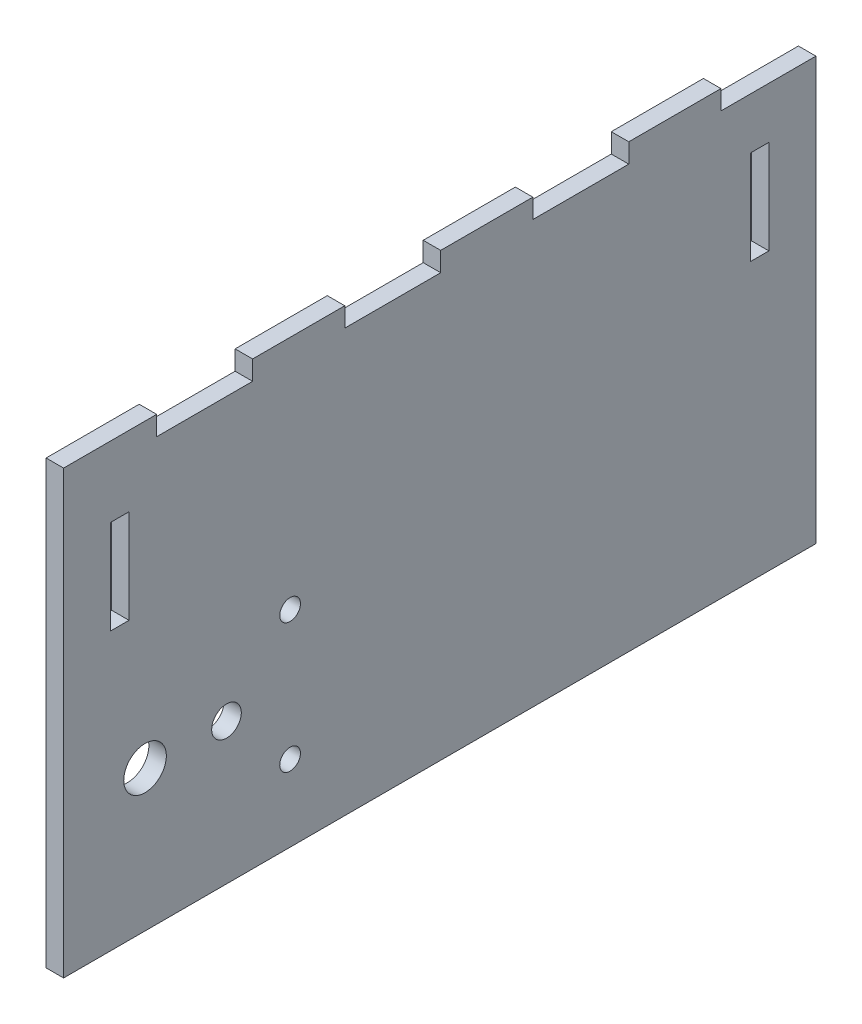
from build123d import *

# Parameters (mm, degrees)
BOSS_EXTRUDE1_DEPTH = 2.3622
CUT_EXTRUDE1_REACH  = 4.362
SKETCH2_R           = 1.4
SKETCH2_R_2         = 2
SKETCH2_R_3         = 2.876999961
CUT_EXTRUDE2_DEPTH  = 3.3622
SKETCH4_W           = 2.4892
SKETCH4_H           = 12.7
CUT_EXTRUDE3_DEPTH  = 3.3622


with BuildPart() as part:
    # Sketch1 → Boss-Extrude1 (new body)
    with BuildSketch(Plane(origin=(0, 0, 0), x_dir=(0, 0, -1), z_dir=(1, 0, 0))):
        Polygon((0, 0), (0, 59.6392), (12.7, 59.6392), (12.7, 57.15), (25.4, 57.15), (25.4, 59.6392), (38.1, 59.6392), (38.1, 57.15), (50.8, 57.15), (50.8, 59.6392), (63.5, 59.6392), (63.5, 57.15), (76.2, 57.15), (76.2, 59.6392), (88.9, 59.6392), (88.9, 57.15), (101.6, 57.15), (101.6, 0), align=None)
    extrude(amount=BOSS_EXTRUDE1_DEPTH)

    # Sketch2 → Cut-Extrude1 (cut, up to next)
    with BuildSketch(Plane(origin=(2.3622, 0, 0), x_dir=(0, 0, -1), z_dir=(1, 0, 0)), mode=Mode.PRIVATE) as cut_extrude1_sk1:
        with Locations((30.59102, 10.3)):
            Circle(SKETCH2_R)
    cut_extrude1_tool1 = extrude(cut_extrude1_sk1.sketch, amount=-CUT_EXTRUDE1_REACH, mode=Mode.PRIVATE) & part.part
    add(cut_extrude1_tool1.solids().sort_by_distance((2.3622, 10.3, -30.59102))[0], mode=Mode.SUBTRACT)
    # Sketch2 → Cut-Extrude1 (cut, up to next)
    with BuildSketch(Plane(origin=(2.3622, 0, 0), x_dir=(0, 0, -1), z_dir=(1, 0, 0)), mode=Mode.PRIVATE) as cut_extrude1_sk2:
        with Locations((30.59102, 27.8)):
            Circle(SKETCH2_R)
    cut_extrude1_tool2 = extrude(cut_extrude1_sk2.sketch, amount=-CUT_EXTRUDE1_REACH, mode=Mode.PRIVATE) & part.part
    add(cut_extrude1_tool2.solids().sort_by_distance((2.3622, 27.8, -30.59102))[0], mode=Mode.SUBTRACT)
    # Sketch2 → Cut-Extrude1 (cut, up to next)
    with BuildSketch(Plane(origin=(2.3622, 0, 0), x_dir=(0, 0, -1), z_dir=(1, 0, 0)), mode=Mode.PRIVATE) as cut_extrude1_sk3:
        with Locations((22.0000034, 19.05)):
            Circle(SKETCH2_R_2)
    cut_extrude1_tool3 = extrude(cut_extrude1_sk3.sketch, amount=-CUT_EXTRUDE1_REACH, mode=Mode.PRIVATE) & part.part
    add(cut_extrude1_tool3.solids().sort_by_distance((2.3622, 19.05, -22.000003))[0], mode=Mode.SUBTRACT)
    # Sketch2 → Cut-Extrude1 (cut, up to next)
    with BuildSketch(Plane(origin=(2.3622, 0, 0), x_dir=(0, 0, -1), z_dir=(1, 0, 0)), mode=Mode.PRIVATE) as cut_extrude1_sk4:
        with Locations((11, 19.05)):
            Circle(SKETCH2_R_3)
    cut_extrude1_tool4 = extrude(cut_extrude1_sk4.sketch, amount=-CUT_EXTRUDE1_REACH, mode=Mode.PRIVATE) & part.part
    add(cut_extrude1_tool4.solids().sort_by_distance((2.3622, 19.05, -11))[0], mode=Mode.SUBTRACT)

    # Sketch3 → Cut-Extrude2 (cut, through all)
    with BuildSketch(Plane(origin=(2.3622, 0, 0), x_dir=(0, 0, -1), z_dir=(1, 0, 0))):
        Polygon((12.7, 57.15), (12.7, 59.6392), (12.573, 59.6392), (12.573, 57.023), (25.527, 57.023), (25.527, 59.6392), (25.4, 59.6392), (25.4, 57.15), align=None)
        Polygon((38.1, 59.6392), (37.973, 59.6392), (37.973, 57.023), (50.927, 57.023), (50.927, 59.6392), (50.8, 59.6392), (50.8, 57.15), (38.1, 57.15), align=None)
        Polygon((63.5, 59.6392), (63.373, 59.6392), (63.373, 57.023), (76.327, 57.023), (76.327, 59.6392), (76.2, 59.6392), (76.2, 57.15), (63.5, 57.15), align=None)
        Polygon((88.9, 59.6392), (88.773, 59.6392), (88.773, 57.023), (101.6, 57.023), (101.6, 57.15), (88.9, 57.15), align=None)
    extrude(amount=-CUT_EXTRUDE2_DEPTH, mode=Mode.SUBTRACT)

    # Sketch4 → Cut-Extrude3 (cut, through all)
    with BuildSketch(Plane(origin=(2.3622, 0, 0), x_dir=(0, 0, -1), z_dir=(1, 0, 0))):
        with Locations((7.5946, 43.7642)):
            Rectangle(SKETCH4_W, SKETCH4_H)
        with Locations((94.0054, 43.7642)):
            Rectangle(SKETCH4_W, SKETCH4_H)
    extrude(amount=-CUT_EXTRUDE3_DEPTH, mode=Mode.SUBTRACT)


solid = part.part
